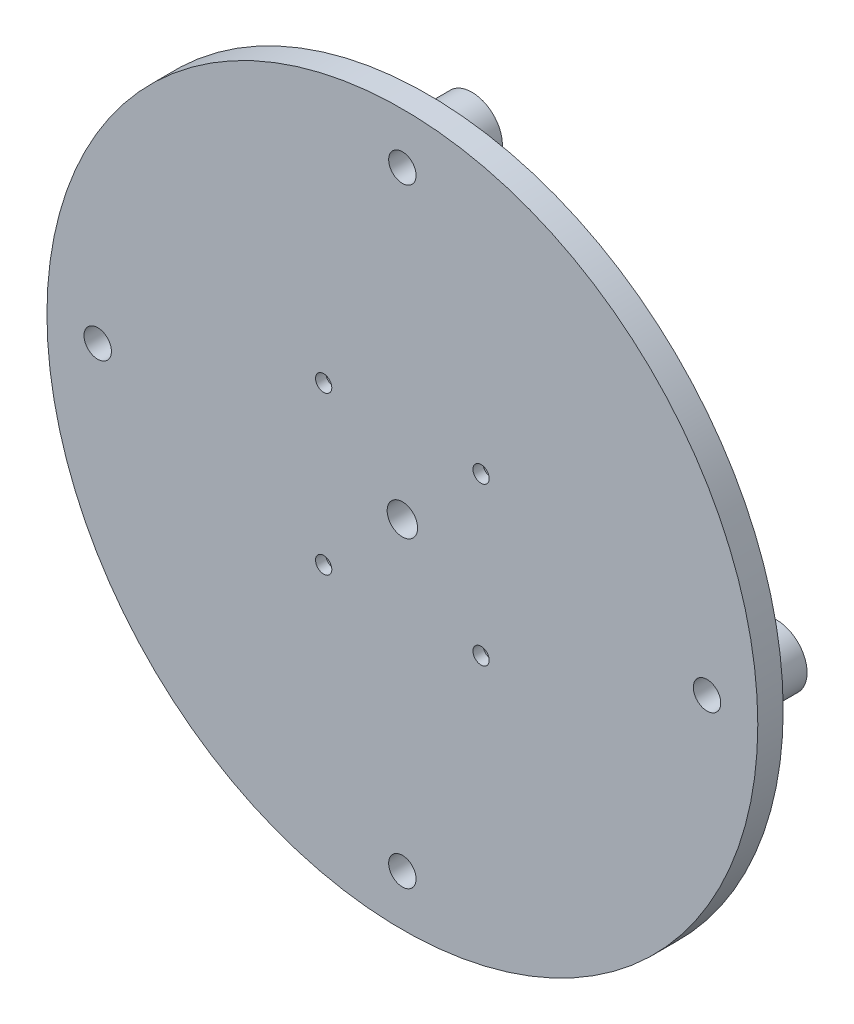
from build123d import *

# Parameters (mm, degrees)
SKETCH1_R           = 70
BOSS_EXTRUDE1_DEPTH = 5
SKETCH2_R           = 1.6
CUT_EXTRUDE1_DEPTH  = 15
SKETCH3_R           = 3
CUT_EXTRUDE2_DEPTH  = 5
SKETCH4_R           = 1.6
CUT_EXTRUDE3_DEPTH  = 5
SKETCH5_R           = 2.8
CUT_EXTRUDE4_DEPTH  = 3
SKETCH6_R           = 6
BOSS_EXTRUDE2_DEPTH = 8.7
SKETCH7_R           = 1.6
CUT_EXTRUDE5_DEPTH  = 15
SKETCH8_R           = 2.7
CUT_EXTRUDE6_DEPTH  = 4


with BuildPart() as part:
    # Sketch1 → Boss-Extrude1 (new body)
    with BuildSketch(Plane.XY):
        Circle(SKETCH1_R)
    extrude(amount=BOSS_EXTRUDE1_DEPTH)

    # Sketch2 → Cut-Extrude1 (cut)
    with BuildSketch(Plane.XY.offset(5)):
        with Locations((0, 60)):
            Circle(SKETCH2_R)
        with Locations((60, 0)):
            Circle(SKETCH2_R)
        with Locations((0, -60)):
            Circle(SKETCH2_R)
        with Locations((-60, 0)):
            Circle(SKETCH2_R)
    extrude(amount=-CUT_EXTRUDE1_DEPTH, mode=Mode.SUBTRACT)

    # Sketch3 → Cut-Extrude2 (cut)
    with BuildSketch(Plane.XY.offset(5)):
        Circle(SKETCH3_R)
    extrude(amount=-CUT_EXTRUDE2_DEPTH, mode=Mode.SUBTRACT)

    # Sketch4 → Cut-Extrude3 (cut)
    with BuildSketch(Plane.XY.offset(5)):
        with Locations((-15.5, 15.5)):
            Circle(SKETCH4_R)
        with Locations((15.5, 15.5)):
            Circle(SKETCH4_R)
        with Locations((15.5, -15.5)):
            Circle(SKETCH4_R)
        with Locations((-15.5, -15.5)):
            Circle(SKETCH4_R)
    extrude(amount=-CUT_EXTRUDE3_DEPTH, mode=Mode.SUBTRACT)

    # Sketch5 → Cut-Extrude4 (cut)
    with BuildSketch(Plane(origin=(0, 0, 0), x_dir=(-1, 0, 0), z_dir=(0, 0, -1))):
        with Locations((-15.5, 15.5)):
            Circle(SKETCH5_R)
        with Locations((15.5, 15.5)):
            Circle(SKETCH5_R)
        with Locations((15.5, -15.5)):
            Circle(SKETCH5_R)
        with Locations((-15.5, -15.5)):
            Circle(SKETCH5_R)
    extrude(amount=-CUT_EXTRUDE4_DEPTH, mode=Mode.SUBTRACT)

    # Sketch6 → Boss-Extrude2 (add)
    with BuildSketch(Plane(origin=(0, 0, 0), x_dir=(-1, 0, 0), z_dir=(0, 0, -1))):
        with Locations((0, 60)):
            Circle(SKETCH6_R)
        with Locations((60, 0)):
            Circle(SKETCH6_R)
        with Locations((0, -60)):
            Circle(SKETCH6_R)
        with Locations((-60, 0)):
            Circle(SKETCH6_R)
    extrude(amount=BOSS_EXTRUDE2_DEPTH)

    # Sketch7 → Cut-Extrude5 (cut)
    with BuildSketch(Plane.XY.offset(5)):
        with Locations((0, -60)):
            Circle(SKETCH7_R)
        with Locations((-60, 0)):
            Circle(SKETCH7_R)
        with Locations((0, 60)):
            Circle(SKETCH7_R)
        with Locations((60, 0)):
            Circle(SKETCH7_R)
    extrude(amount=-CUT_EXTRUDE5_DEPTH, mode=Mode.SUBTRACT)

    # Sketch8 → Cut-Extrude6 (cut)
    with BuildSketch(Plane.XY.offset(5)):
        with Locations((0, 60)):
            Circle(SKETCH8_R)
        with Locations((60, 0)):
            Circle(SKETCH8_R)
        with Locations((0, -60)):
            Circle(SKETCH8_R)
        with Locations((-60, 0)):
            Circle(SKETCH8_R)
    extrude(amount=-CUT_EXTRUDE6_DEPTH, mode=Mode.SUBTRACT)


solid = part.part
